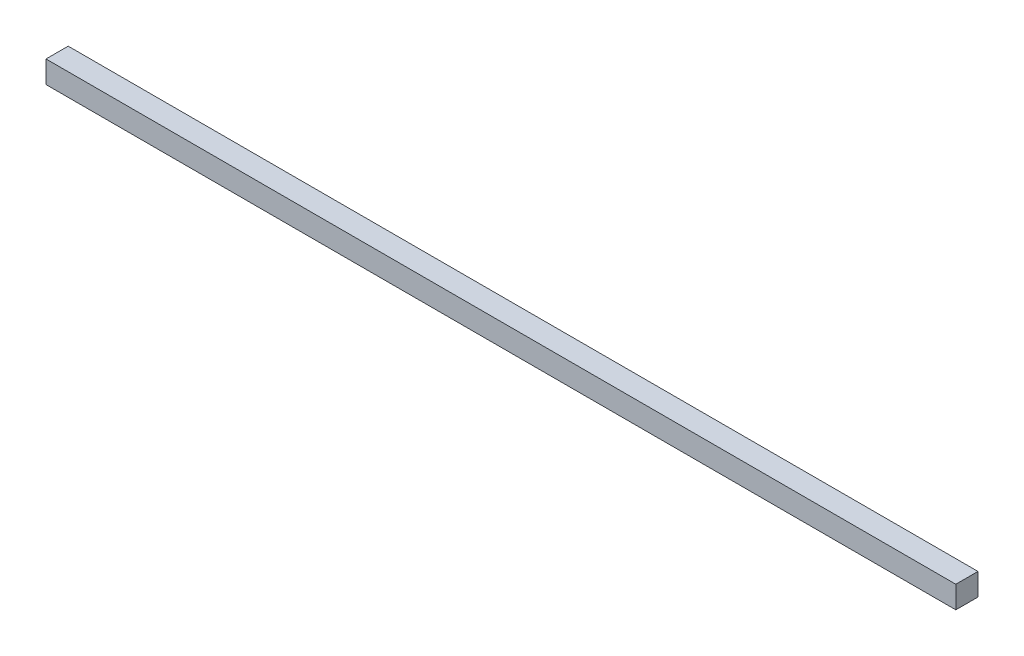
from build123d import *

# Parameters (mm, degrees)
SKETCH1_W           = 410
SKETCH1_H           = 10
BOSS_EXTRUDE1_DEPTH = 10


with BuildPart() as part:
    # Sketch1 → Boss-Extrude1 (new body)
    with BuildSketch(Plane(origin=(0, 0, 0), x_dir=(1, 0, 0), z_dir=(0, 1, 0))):
        Rectangle(SKETCH1_W, SKETCH1_H)
    extrude(amount=BOSS_EXTRUDE1_DEPTH)


solid = part.part
